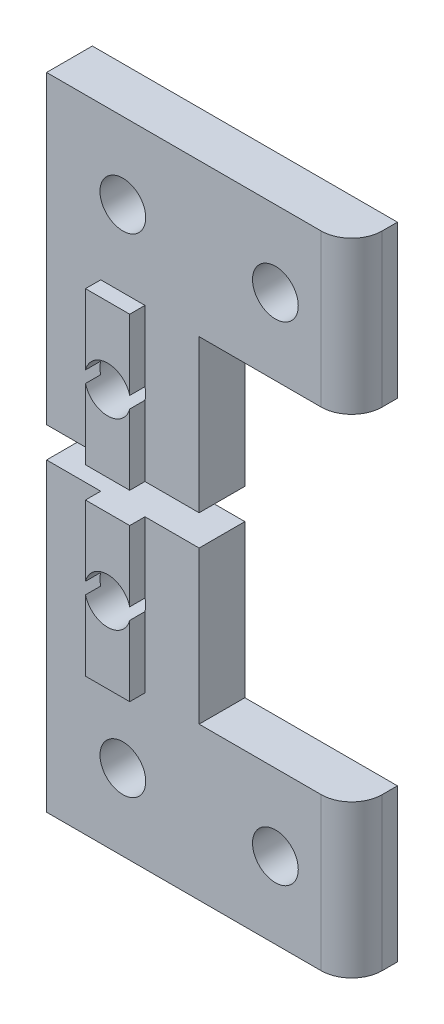
from build123d import *

# Parameters (mm, degrees)
BOSS_EXTRU_1_DEPTH      = 3
ESQUISSE2_W             = 2.9
ESQUISSE2_H             = 10
BOSS_EXTRU_2_DEPTH      = 1
ESQUISSE4_R             = 1.5
ENL_V_MAT_EXTRU_2_DEPTH = 5
CONG_1_R                = 2


with BuildPart() as part:
    # Esquisse1 → Boss.-Extru.1 (new body)
    with BuildSketch(Plane.XY):
        Polygon((0, 0), (20, 0), (20, 10), (10, 10), (10, 20), (0, 20), align=None)
    extrude(amount=BOSS_EXTRU_1_DEPTH)

    # Esquisse2 → Boss.-Extru.2 (add)
    with BuildSketch(Plane.XY.offset(3)):
        with Locations((5, 15)):
            Rectangle(ESQUISSE2_W, ESQUISSE2_H)
    extrude(amount=BOSS_EXTRU_2_DEPTH)

    # Esquisse4 → Enlèv. mat.-Extru.2 (cut, through all)
    with BuildSketch(Plane.XY.offset(4)):
        with Locations((5, 15)):
            Circle(ESQUISSE4_R)
        with Locations((5, 5)):
            Circle(ESQUISSE4_R)
        with Locations((15, 5)):
            Circle(ESQUISSE4_R)
    extrude(amount=-ENL_V_MAT_EXTRU_2_DEPTH, mode=Mode.SUBTRACT)

    # Congé1
    cong_1_edges = [part.edges().sort_by_distance(p)[0] for p in [
        (20, 5, 3),
    ]]
    fillet(cong_1_edges, radius=CONG_1_R)


with BuildPart() as body_2:
    # Symétrie2: mirrored copy
    add(part.part.mirror(Plane.ZX.offset(21)))


solid = Compound([part.part, body_2.part])
